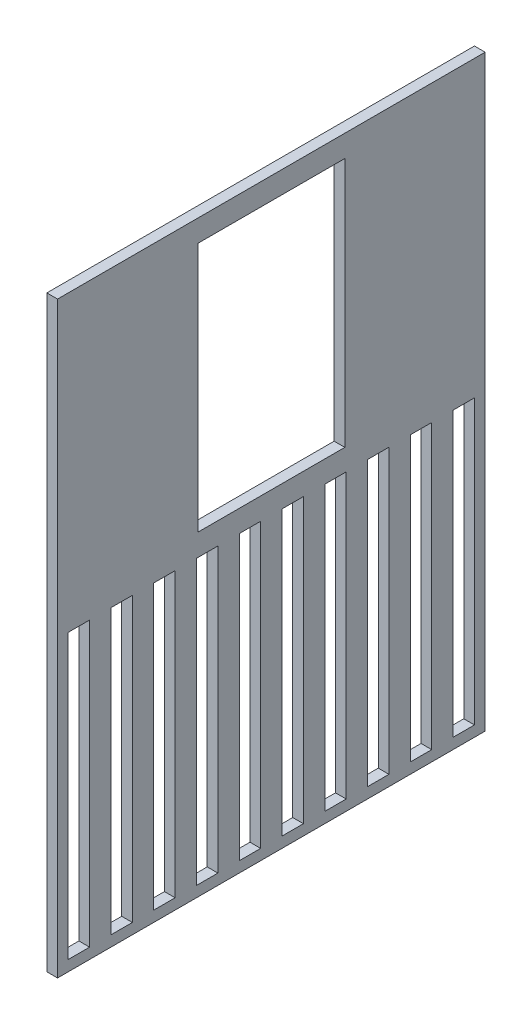
from build123d import *

# Parameters (mm, degrees)
SKETCH1_W           = 155
SKETCH1_H           = 110
BOSS_EXTRUDE1_DEPTH = 80
SKETCH2_W           = 151
SKETCH2_H           = 106
CUT_EXTRUDE1_DEPTH  = 78
SKETCH3_R           = 2.5
CUT_EXTRUDE2_DEPTH  = 2
SKETCH7_R           = 1.6
CUT_EXTRUDE7_DEPTH  = 2
SKETCH4_W           = 27.5
SKETCH4_H           = 46.8
CUT_EXTRUDE8_DEPTH  = 2
SKETCH8_W           = 4
SKETCH8_H           = 53
CUT_EXTRUDE9_DEPTH  = 2
SKETCH9_W           = 14
SKETCH9_H           = 14
CUT_EXTRUDE10_DEPTH = 2
SKETCH10_W          = 25.2
SKETCH10_H          = 71.2
SKETCH10_R          = 1.25
CUT_EXTRUDE12_DEPTH = 2
SKETCH11_R          = 2.5
SKETCH11_R_2        = 4.5
CUT_EXTRUDE13_DEPTH = 2
SKETCH12_W          = 153
SKETCH12_H          = 110
CUT_EXTRUDE14_DEPTH = 80


with BuildPart() as part:
    # Sketch1 → Boss-Extrude1 (new body)
    with BuildSketch(Plane.XY):
        with Locations((77.5, 55)):
            Rectangle(SKETCH1_W, SKETCH1_H)
    extrude(amount=BOSS_EXTRUDE1_DEPTH)

    # Sketch2 → Cut-Extrude1 (cut)
    with BuildSketch(Plane.XY.offset(80)):
        with Locations((77.5, 55)):
            Rectangle(SKETCH2_W, SKETCH2_H)
    extrude(amount=-CUT_EXTRUDE1_DEPTH, mode=Mode.SUBTRACT)

    # Sketch3 → Cut-Extrude2 (cut)
    with BuildSketch(Plane.XY.offset(2)):
        with Locations((145, 100.5)):
            Circle(SKETCH3_R)
        with Locations((145, 9.5)):
            Circle(SKETCH3_R)
        with Locations((10, 9.5)):
            Circle(SKETCH3_R)
        with Locations((10, 100.5)):
            Circle(SKETCH3_R)
    extrude(amount=-CUT_EXTRUDE2_DEPTH, mode=Mode.SUBTRACT)

    # Sketch7 → Cut-Extrude7 (cut)
    with BuildSketch(Plane(origin=(0, 110, 0), x_dir=(1, 0, 0), z_dir=(0, 1, 0))):
        with Locations((44.48, -20.14450396)):
            Circle(SKETCH7_R)
        with Locations((95.28, -17.14)):
            Circle(SKETCH7_R)
        with Locations((95.28, -62.86)):
            Circle(SKETCH7_R)
        with Locations((44.48, -47.62)):
            Circle(SKETCH7_R)
    extrude(amount=-CUT_EXTRUDE7_DEPTH, mode=Mode.SUBTRACT)

    # Sketch4 → Cut-Extrude8 (cut)
    with BuildSketch(Plane(origin=(155, 0, 0), x_dir=(0, 0, -1), z_dir=(1, 0, 0))):
        with Locations((-40, 82.5)):
            Rectangle(SKETCH4_W, SKETCH4_H)
    extrude(amount=-CUT_EXTRUDE8_DEPTH, mode=Mode.SUBTRACT)

    # Sketch8 → Cut-Extrude9 (cut)
    with BuildSketch(Plane(origin=(155, 0, 0), x_dir=(0, 0, -1), z_dir=(1, 0, 0))):
        with Locations((-68, 28.5)):
            Rectangle(SKETCH8_W, SKETCH8_H)
        with Locations((-76, 28.5)):
            Rectangle(SKETCH8_W, SKETCH8_H)
        with Locations((-60, 28.5)):
            Rectangle(SKETCH8_W, SKETCH8_H)
        with Locations((-52, 28.5)):
            Rectangle(SKETCH8_W, SKETCH8_H)
        with Locations((-44, 28.5)):
            Rectangle(SKETCH8_W, SKETCH8_H)
        with Locations((-36, 28.5)):
            Rectangle(SKETCH8_W, SKETCH8_H)
        with Locations((-28, 28.5)):
            Rectangle(SKETCH8_W, SKETCH8_H)
        with Locations((-20, 28.5)):
            Rectangle(SKETCH8_W, SKETCH8_H)
        with Locations((-12, 28.5)):
            Rectangle(SKETCH8_W, SKETCH8_H)
        with Locations((-4, 28.5)):
            Rectangle(SKETCH8_W, SKETCH8_H)
    extrude(amount=-CUT_EXTRUDE9_DEPTH, mode=Mode.SUBTRACT)

    # Sketch9 → Cut-Extrude10 (cut)
    with BuildSketch(Plane(origin=(0, 110, 0), x_dir=(1, 0, 0), z_dir=(0, 1, 0))):
        with Locations((120, -19)):
            Rectangle(SKETCH9_W, SKETCH9_H)
    extrude(amount=-CUT_EXTRUDE10_DEPTH, mode=Mode.SUBTRACT)

    # Sketch10 → Cut-Extrude12 (cut)
    with BuildSketch(Plane.ZY):
        with Locations((58, 55)):
            Rectangle(SKETCH10_W, SKETCH10_H)
        with Locations((42.5, 92.5)):
            Circle(SKETCH10_R)
        with Locations((73.5, 92.5)):
            Circle(SKETCH10_R)
        with Locations((42.5, 17.5)):
            Circle(SKETCH10_R)
        with Locations((73.5, 17.5)):
            Circle(SKETCH10_R)
    extrude(amount=-CUT_EXTRUDE12_DEPTH, mode=Mode.SUBTRACT)

    # Sketch11 → Cut-Extrude13 (cut)
    with BuildSketch(Plane.ZY):
        with Locations((20, 55)):
            Circle(SKETCH11_R)
        with Locations((20, 40)):
            Circle(SKETCH11_R)
        with Locations((20, 25)):
            Circle(SKETCH11_R)
        with Locations((20, 82.5)):
            Circle(SKETCH11_R_2)
    extrude(amount=-CUT_EXTRUDE13_DEPTH, mode=Mode.SUBTRACT)

    # Sketch12 → Cut-Extrude14 (cut)
    with BuildSketch(Plane.XY.offset(80)):
        with Locations((76.5, 55)):
            Rectangle(SKETCH12_W, SKETCH12_H)
    extrude(amount=-CUT_EXTRUDE14_DEPTH, mode=Mode.SUBTRACT)


solid = part.part
